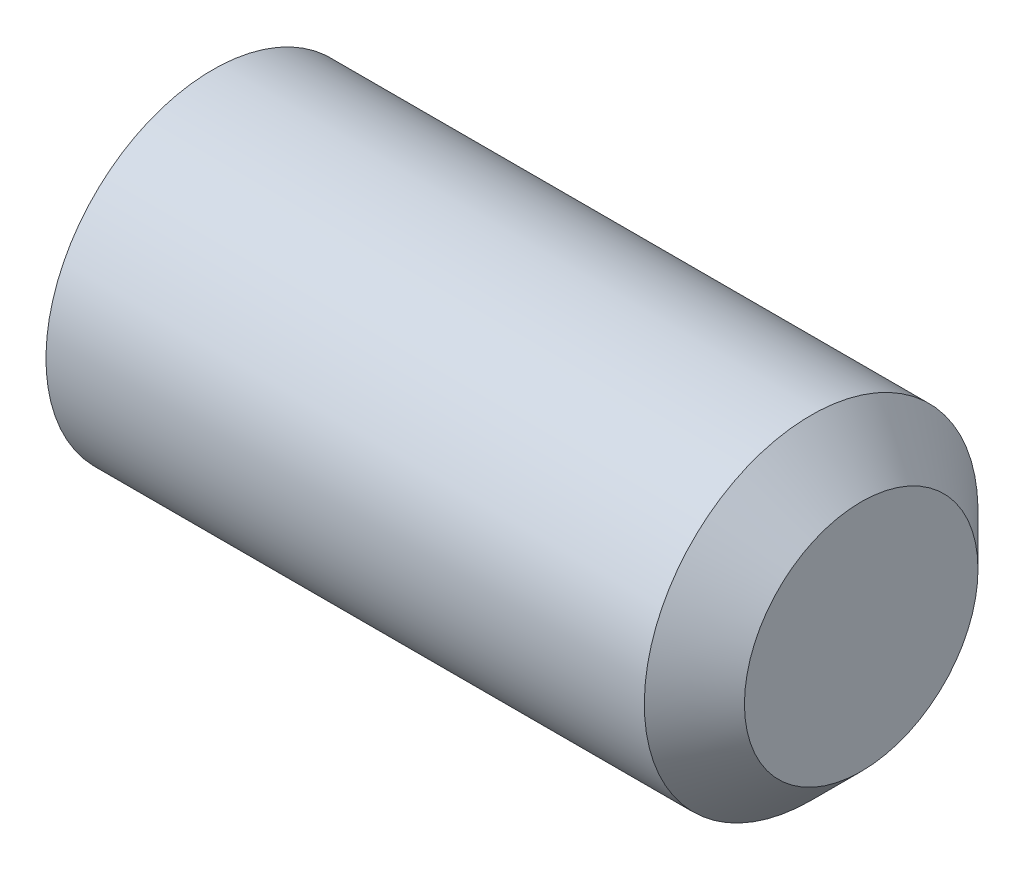
from build123d import *

# Parameters (mm, degrees)
CUT_EXTRUDE1_DEPTH = 3


with BuildPart() as part:
    # Sketch1 → Revolve1 (revolve)
    with BuildSketch(Plane.XY):
        Polygon((10, 0), (10, -1.75), (9.25, -2.5), (0.283190307, -2.5), (0, -2.0095), (0, -1.443375673), (0.833333333, 0), align=None)
    revolve(axis=Axis((0.833333333, 0, 0), (1, 0, 0)))

    # Sketch2 → Cut-Extrude1 (cut)
    with BuildSketch(Plane(origin=(0, 0, 0), x_dir=(0, 0, -1), z_dir=(1, 0, 0))):
        Polygon((-1.443375673, 0), (-0.721687836, -1.25), (0.721687836, -1.25), (1.443375673, 0), (0.721687836, 1.25), (-0.721687836, 1.25), align=None)
    extrude(amount=CUT_EXTRUDE1_DEPTH, mode=Mode.SUBTRACT)


solid = part.part
